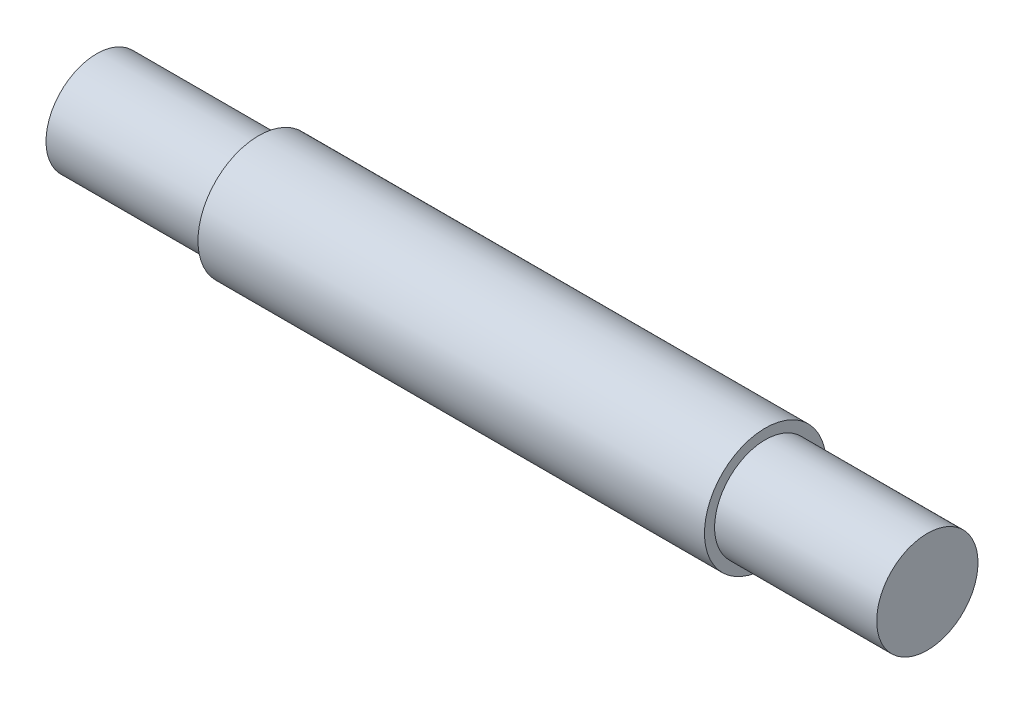
from build123d import *

# Parameters (mm, degrees)
IZIM1_R                     = 6
Y_KSEKLIK_EKSTR_ZYON1_DEPTH = 50
IZIM2_R                     = 5
Y_KSEKLIK_EKSTR_ZYON2_DEPTH = 16
IZIM3_R                     = 5
Y_KSEKLIK_EKSTR_ZYON3_DEPTH = 16


with BuildPart() as part:
    # Çizim1 → Yükseklik-Ekstrüzyon1 (new body)
    with BuildSketch(Plane(origin=(0, 0, 0), x_dir=(0, 0, -1), z_dir=(1, 0, 0))):
        Circle(IZIM1_R)
    extrude(amount=Y_KSEKLIK_EKSTR_ZYON1_DEPTH)

    # Çizim2 → Yükseklik-Ekstrüzyon2 (add)
    with BuildSketch(Plane.ZY):
        Circle(IZIM2_R)
    extrude(amount=Y_KSEKLIK_EKSTR_ZYON2_DEPTH)

    # Çizim3 → Yükseklik-Ekstrüzyon3 (add)
    with BuildSketch(Plane(origin=(50, 0, 0), x_dir=(0, 0, -1), z_dir=(1, 0, 0))):
        Circle(IZIM3_R)
    extrude(amount=Y_KSEKLIK_EKSTR_ZYON3_DEPTH)


solid = part.part
